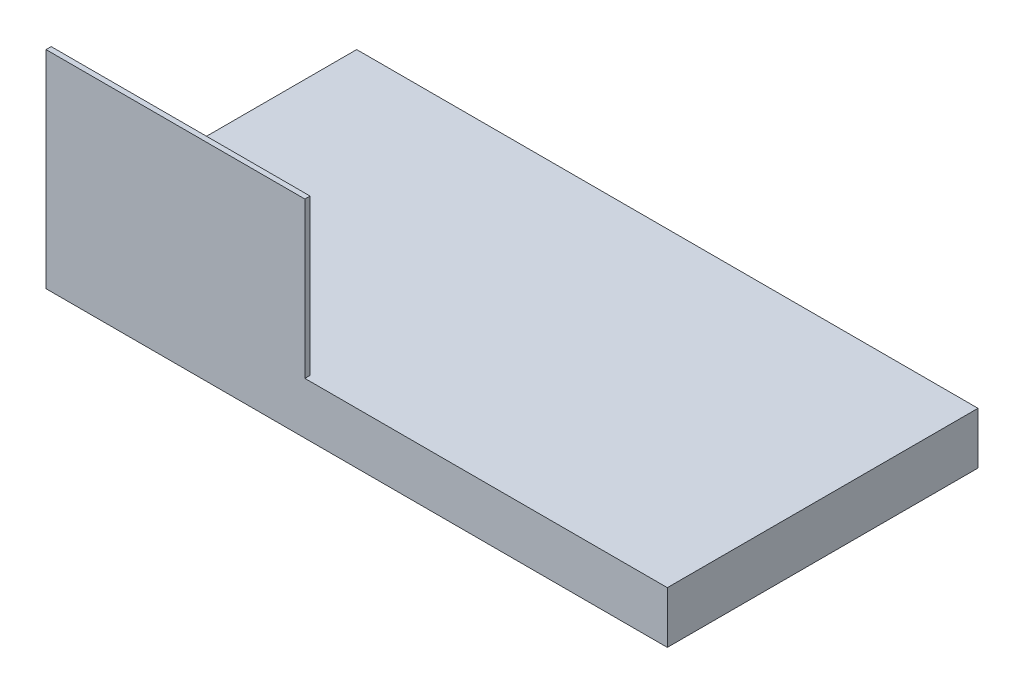
from build123d import *

# Parameters (mm, degrees)
SKETCH1_W           = 120
SKETCH1_H           = 60
BOSS_EXTRUDE1_DEPTH = 10
SKETCH3_W           = 50
SKETCH3_H           = 1
EXTRUDE_THIN4_DEPTH = 30


with BuildPart() as part:
    # Sketch1 → Boss-Extrude1 (new body)
    with BuildSketch(Plane(origin=(0, 0, 0), x_dir=(1, 0, 0), z_dir=(0, 1, 0))):
        Rectangle(SKETCH1_W, SKETCH1_H)
    extrude(amount=BOSS_EXTRUDE1_DEPTH)

    # Sketch3 → Extrude-Thin4 (add)
    with BuildSketch(Plane(origin=(0, 10, 0), x_dir=(1, 0, 0), z_dir=(0, 1, 0))):
        with Locations((-35, -29.5)):
            Rectangle(SKETCH3_W, SKETCH3_H)
    extrude(amount=EXTRUDE_THIN4_DEPTH)


solid = part.part
